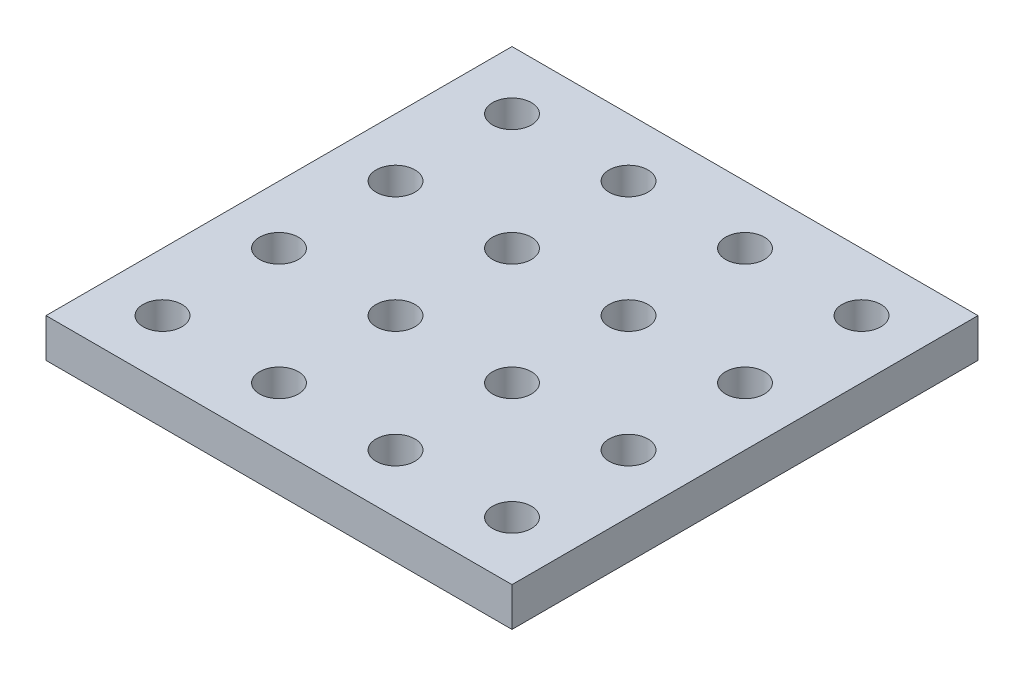
from build123d import *

# Parameters (mm, degrees)
SKETCH1_W            = 120
SKETCH1_H            = 120
BOSS_EXTRUDE1_DEPTH  = 10
SKETCH2_R            = 5
CUT_EXTRUDE1_DEPTH   = 11
LPATTERN1_COUNT      = 4
LPATTERN1_PITCH      = 30
LPATTERN1_COUNT_DIR2 = 4
LPATTERN1_PITCH_DIR2 = 30


with BuildPart() as part:
    # Sketch1 → Boss-Extrude1 (new body)
    with BuildSketch(Plane(origin=(0, 0, 0), x_dir=(1, 0, 0), z_dir=(0, 1, 0))):
        with Locations((60, 60)):
            Rectangle(SKETCH1_W, SKETCH1_H)
    extrude(amount=BOSS_EXTRUDE1_DEPTH)

    # Sketch2 → Cut-Extrude1 (cut, through all)
    with BuildSketch(Plane(origin=(0, 10, 0), x_dir=(1, 0, 0), z_dir=(0, 1, 0))):
        with Locations((15, 15)):
            Circle(SKETCH2_R)
    cut_extrude1 = extrude(amount=-CUT_EXTRUDE1_DEPTH, mode=Mode.SUBTRACT)

    # LPattern1: Cut-Extrude1 4 × 4
    with Locations(*[(i * LPATTERN1_PITCH, 0, -j * LPATTERN1_PITCH_DIR2) for i in range(LPATTERN1_COUNT) for j in range(LPATTERN1_COUNT_DIR2) if (i, j) != (0, 0)]):
        add(cut_extrude1, mode=Mode.SUBTRACT)


solid = part.part
